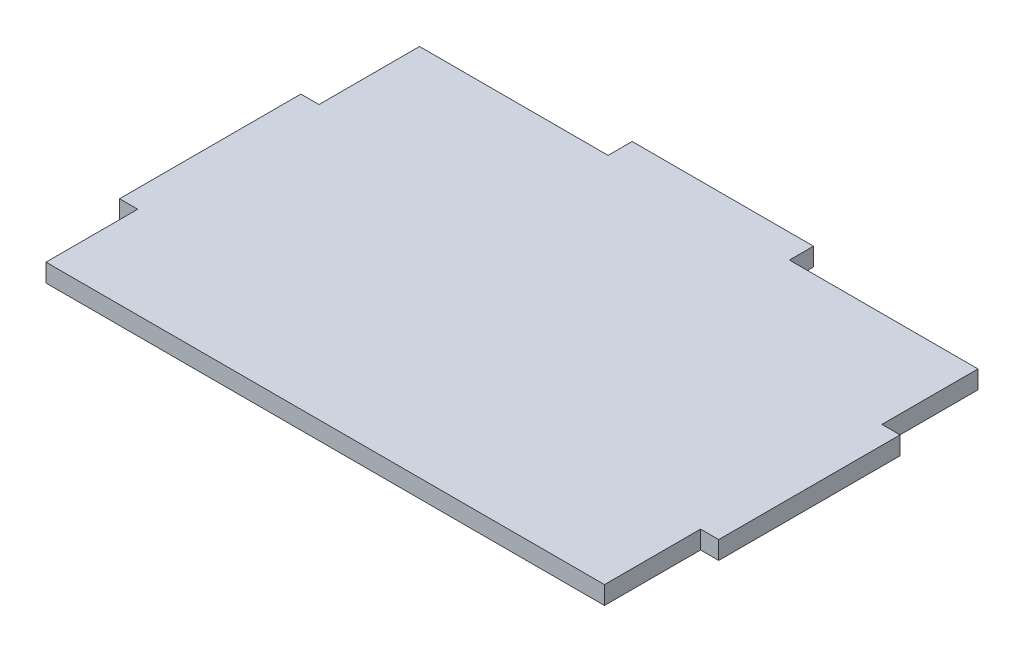
from build123d import *

# Parameters (mm, degrees)
BOSS_EXTRU_1_DEPTH = 5


with BuildPart() as part:
    # Esquisse1 → Boss.-Extru.1 (new body)
    with BuildSketch(Plane(origin=(0, 0, 0), x_dir=(1, 0, 0), z_dir=(0, 1, 0))):
        Polygon((77, -51.5), (77, -25), (82, -25), (82, 25), (77, 25), (77, 51.5), (25, 51.5), (25, 58.129676011), (-25, 58.129676011), (-25, 51.5), (-77, 51.5), (-77, 23.781867572), (-82, 23.781867572), (-82, -26.218132428), (-77, -26.218132428), (-77, -51.5), align=None)
    extrude(amount=BOSS_EXTRU_1_DEPTH)


solid = part.part
